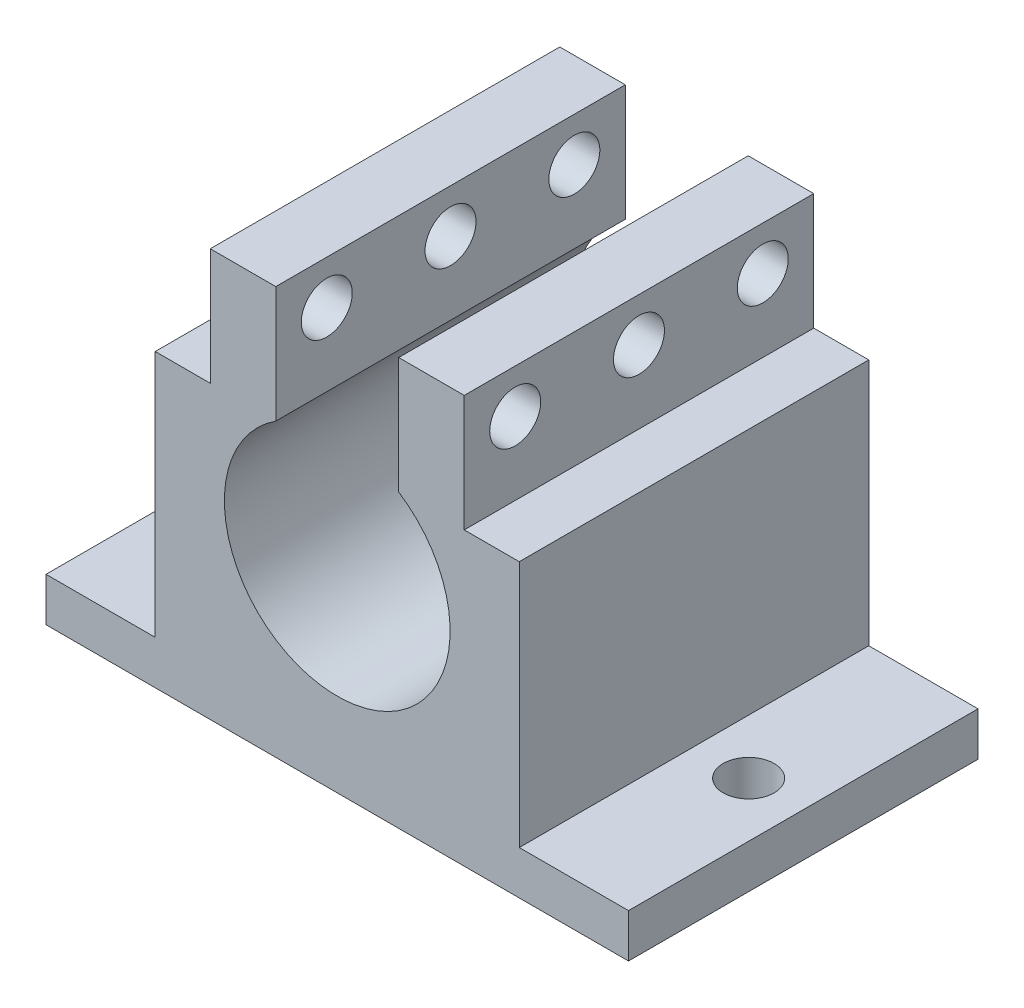
from build123d import *

# Parameters (mm, degrees)
SALIENTE_EXTRUIR2_DEPTH = 24
CROQUIS2_W              = 4.5
CROQUIS2_H              = 8
SALIENTE_EXTRUIR3_DEPTH = 24
CROQUIS3_W              = 7.5
CROQUIS3_H              = 3
SALIENTE_EXTRUIR4_DEPTH = 24
CORTAR_EXTRUIR1_START   = -8.720486
CROQUIS4_R              = 1.75
CORTAR_EXTRUIR1_DEPTH   = 17.440972
CROQUIS5_R              = 1.75
CORTAR_EXTRUIR2_DEPTH   = 10


with BuildPart() as part:
    # Croquis1 → Saliente-Extruir2 (new body)
    with BuildSketch(Plane.XY):
        with BuildLine():
            Line((-4.220485754, 10), (-12.5, 10))
            Line((-12.5, 10), (-12.5, -10))
            Line((-12.5, -10), (12.5, -10))
            Line((12.5, -10), (12.5, 10))
            Line((12.5, 10), (4.220485754, 10))
            ThreePointArc((4.220485754, 10), (0, -4.25), (-4.220485754, 10))
        make_face()
    extrude(amount=SALIENTE_EXTRUIR2_DEPTH)

    # Croquis2 → Saliente-Extruir3 (add)
    with BuildSketch(Plane.XY):
        with Locations((-6.470485754, 14)):
            Rectangle(CROQUIS2_W, CROQUIS2_H)
        with Locations((6.470485754, 14)):
            Rectangle(CROQUIS2_W, CROQUIS2_H)
    extrude(amount=SALIENTE_EXTRUIR3_DEPTH)

    # Croquis3 → Saliente-Extruir4 (add)
    with BuildSketch(Plane.XY):
        with Locations((-16.25, -8.5)):
            Rectangle(CROQUIS3_W, CROQUIS3_H)
        with Locations((16.25, -8.5)):
            Rectangle(CROQUIS3_W, CROQUIS3_H)
    extrude(amount=SALIENTE_EXTRUIR4_DEPTH)

    # Croquis4 → Cortar-Extruir1 (cut)
    with BuildSketch(Plane(origin=(0, 0, 0), x_dir=(0, 0, -1), z_dir=(1, 0, 0)).offset(CORTAR_EXTRUIR1_START)):
        with Locations((-20.5, 15)):
            Circle(CROQUIS4_R)
        with Locations((-12, 15)):
            Circle(CROQUIS4_R)
        with Locations((-3.5, 15)):
            Circle(CROQUIS4_R)
    extrude(amount=CORTAR_EXTRUIR1_DEPTH, mode=Mode.SUBTRACT)

    # Croquis5 → Cortar-Extruir2 (cut)
    with BuildSketch(Plane(origin=(0, 0, 0), x_dir=(1, 0, 0), z_dir=(0, 1, 0))):
        with Locations((-16.25, -12)):
            Circle(CROQUIS5_R)
        with Locations((16.25, -12)):
            Circle(CROQUIS5_R)
    extrude(amount=-CORTAR_EXTRUIR2_DEPTH, mode=Mode.SUBTRACT)


solid = part.part
